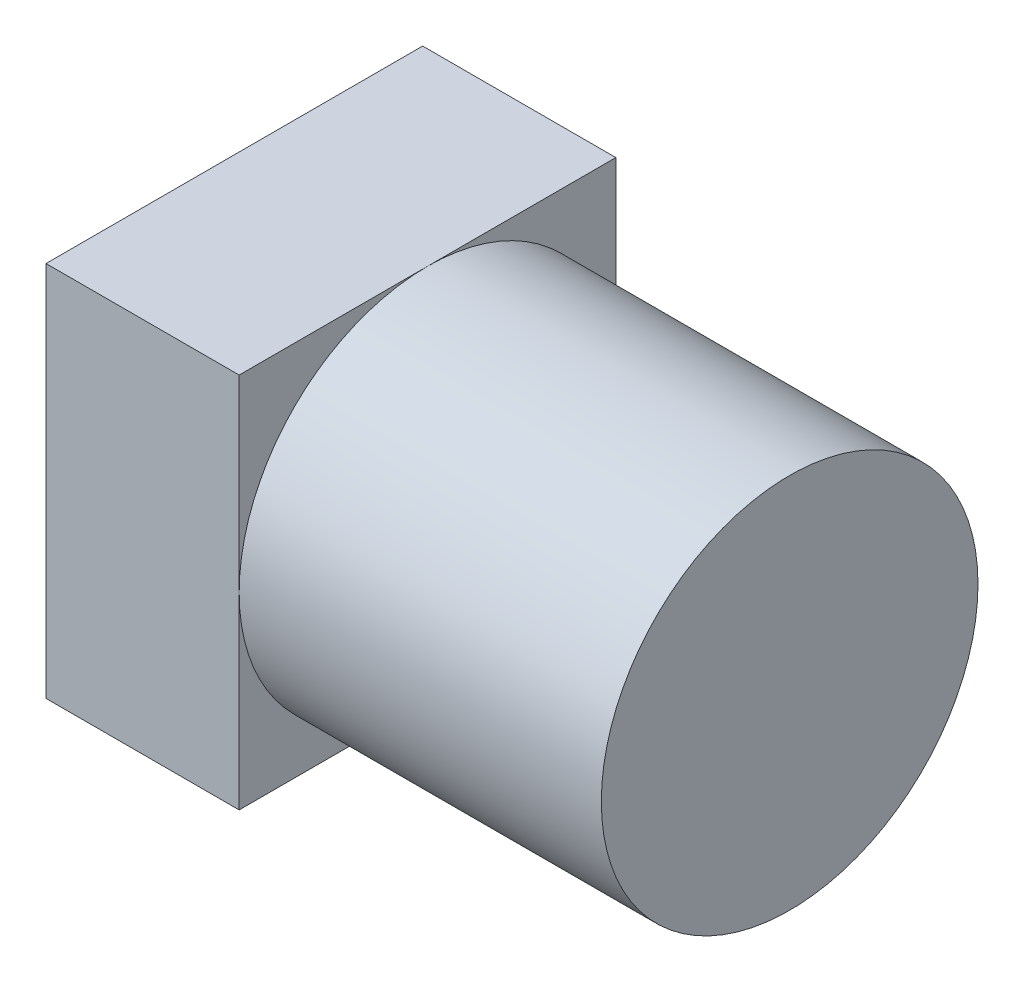
from build123d import *

# Parameters (mm, degrees)
SKETCH1_W           = 15.6
SKETCH1_H           = 15.6
BOSS_EXTRUDE1_DEPTH = 8
SKETCH2_R           = 7.8
BOSS_EXTRUDE2_DEPTH = 15


with BuildPart() as part:
    # Sketch1 → Boss-Extrude1 (new body)
    with BuildSketch(Plane(origin=(0, 0, 0), x_dir=(0, 0, -1), z_dir=(1, 0, 0))):
        Rectangle(SKETCH1_W, SKETCH1_H)
    extrude(amount=BOSS_EXTRUDE1_DEPTH)

    # Sketch2 → Boss-Extrude2 (add)
    with BuildSketch(Plane(origin=(8, 0, 0), x_dir=(0, 0, -1), z_dir=(1, 0, 0))):
        Circle(SKETCH2_R)
    extrude(amount=BOSS_EXTRUDE2_DEPTH)


solid = part.part
